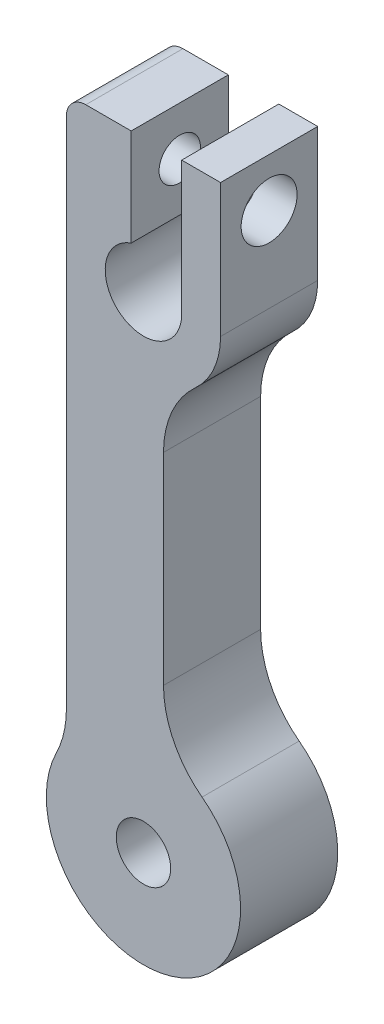
from build123d import *

# Parameters (mm, degrees)
SKETCH1_R                 = 1.778
BOSS_EXTRUDE1_DEPTH       = 6.35
FILLET1_R                 = 1.27
F_6_32_TAPPED_HOLE1_D     = 2.7051
F_6_CLEARANCE_HOLE1_D     = 3.6576
F_6_CLEARANCE_HOLE1_DEPTH = 3.175
F_6_CLEARANCE_HOLE1_TIP   = 1.0988539


with BuildPart() as part:
    # Sketch1 → Boss-Extrude1 (new body)
    with BuildSketch(Plane.XY):
        with BuildLine():
            Line((-5.04, 40.467867395), (-5.04, 31.75))
            Line((-5.04, 31.75), (-5.04, 5.617641854))
            ThreePointArc((-5.04, 5.617641854), (-5.205917611, 4.175551358), (-5.695, 2.808820927))
            ThreePointArc((-5.695, 2.808820927), (1.46358213, -6.179031263), (3.83, 5.064938302))
            ThreePointArc((3.83, 5.064938302), (1.974799916, 7.301272707), (1.31, 10.129876603))
            Line((1.31, 10.129876603), (1.31, 23.320498235))
            ThreePointArc((1.31, 23.320498235), (1.853099889, 25.890013969), (3.389499561, 28.020000975))
            ThreePointArc((3.389499561, 28.020000975), (4.60894119, 29.710573339), (5.04, 31.75))
            Line((5.04, 31.75), (5.04, 40.467867395))
            Line((5.04, 40.467867395), (2.5, 40.467867395))
            Line((2.5, 40.467867395), (2.5, 31.75))
            ThreePointArc((2.5, 31.75), (-1.456880228, 29.718375035), (-0.802, 34.117867395))
            Line((-0.802, 34.117867395), (-0.802, 40.467867395))
            Line((-0.802, 40.467867395), (-5.04, 40.467867395))
        make_face()
        Circle(SKETCH1_R, mode=Mode.SUBTRACT)
    extrude(amount=BOSS_EXTRUDE1_DEPTH)

    # Fillet1
    fillet1_edges = [part.edges().sort_by_distance(p)[0] for p in [
        (-5.04, 40.467867395, 3.175),
    ]]
    fillet(fillet1_edges, radius=FILLET1_R)

    # #6-32 Tapped Hole1 (through all)
    with Locations(Plane.ZY.offset(5.04)):
        with Locations((3.175, 37.292867395)):
            Hole(F_6_32_TAPPED_HOLE1_D / 2)

    # #6 Clearance Hole1
    with Locations(Plane(origin=(5.04, 37.292867395, 3.175), x_dir=(0, 1, 0), z_dir=(1, 0, 0))):
        with Locations((0, 0)):
            Hole(F_6_CLEARANCE_HOLE1_D / 2, depth=F_6_CLEARANCE_HOLE1_DEPTH)
            with Locations((0, 0, -(F_6_CLEARANCE_HOLE1_DEPTH + F_6_CLEARANCE_HOLE1_TIP / 2))):  # 118° drill point
                Cone(0, F_6_CLEARANCE_HOLE1_D / 2, F_6_CLEARANCE_HOLE1_TIP, mode=Mode.SUBTRACT)


solid = part.part
